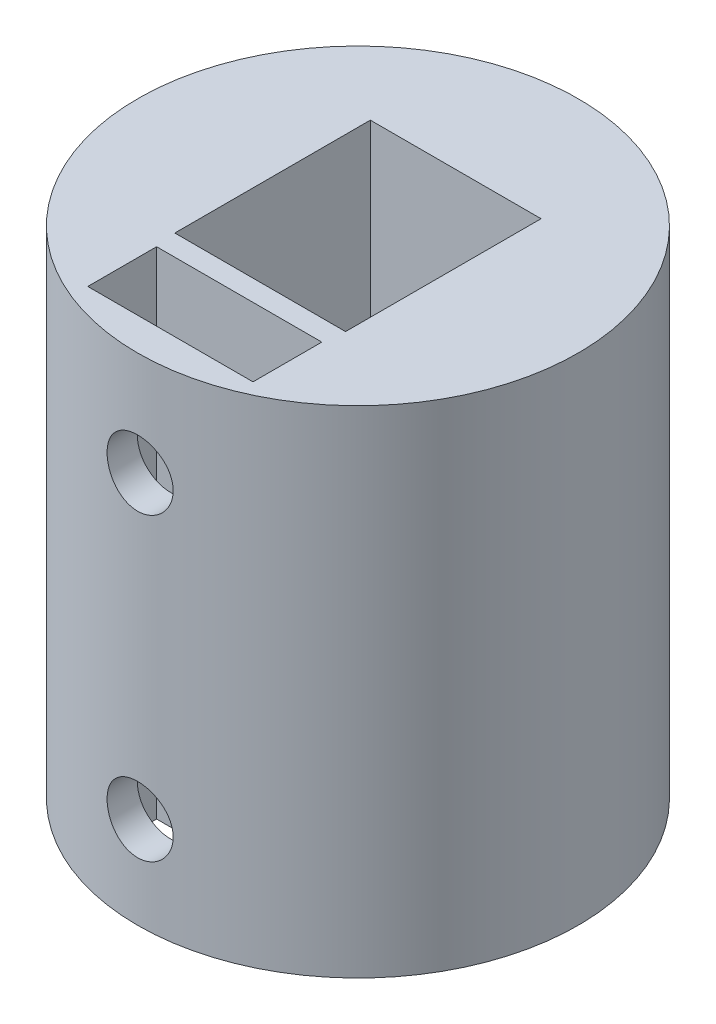
from build123d import *

# Parameters (mm, degrees)
SKETCH1_R           = 8
BOSS_EXTRUDE1_DEPTH = 18
CUT_EXTRUDE1_DEPTH  = 8
SKETCH3_W           = 6.2
SKETCH3_H           = 7.1
CUT_EXTRUDE2_DEPTH  = 8
SKETCH4_W           = 6
SKETCH4_H           = 2.5
CUT_EXTRUDE3_DEPTH  = 20
SKETCH5_R           = 1.2
CUT_EXTRUDE4_DEPTH  = 9


with BuildPart() as part:
    # Sketch1 → Boss-Extrude1 (new body)
    with BuildSketch(Plane(origin=(0, 0, 0), x_dir=(1, 0, 0), z_dir=(0, 1, 0))):
        Circle(SKETCH1_R)
    extrude(amount=BOSS_EXTRUDE1_DEPTH)

    # Sketch2 → Cut-Extrude1 (cut)
    with BuildSketch(Plane.XZ):
        with BuildLine():
            Line((-1.501271778, 1.395952381), (1.501271778, 1.395952381))
            ThreePointArc((1.501271778, 1.395952381), (0, -2.05), (-1.501271778, 1.395952381))
        make_face()
    extrude(amount=-CUT_EXTRUDE1_DEPTH, mode=Mode.SUBTRACT)

    # Sketch3 → Cut-Extrude2 (cut)
    with BuildSketch(Plane(origin=(0, 18, 0), x_dir=(1, 0, 0), z_dir=(0, 1, 0))):
        Rectangle(SKETCH3_W, SKETCH3_H)
    extrude(amount=-CUT_EXTRUDE2_DEPTH, mode=Mode.SUBTRACT)

    # Sketch4 → Cut-Extrude3 (cut)
    with BuildSketch(Plane(origin=(0, 18, 0), x_dir=(1, 0, 0), z_dir=(0, 1, 0))):
        with Locations((0, -5.561582467)):
            Rectangle(SKETCH4_W, SKETCH4_H)
    extrude(amount=-CUT_EXTRUDE3_DEPTH, mode=Mode.SUBTRACT)

    # Sketch5 → Cut-Extrude4 (cut)
    with BuildSketch(Plane.XY.offset(8)):
        with Locations((0, 3.328333926)):
            Circle(SKETCH5_R)
        with Locations((0, 14.225763094)):
            Circle(SKETCH5_R)
    extrude(amount=-CUT_EXTRUDE4_DEPTH, mode=Mode.SUBTRACT)


solid = part.part
